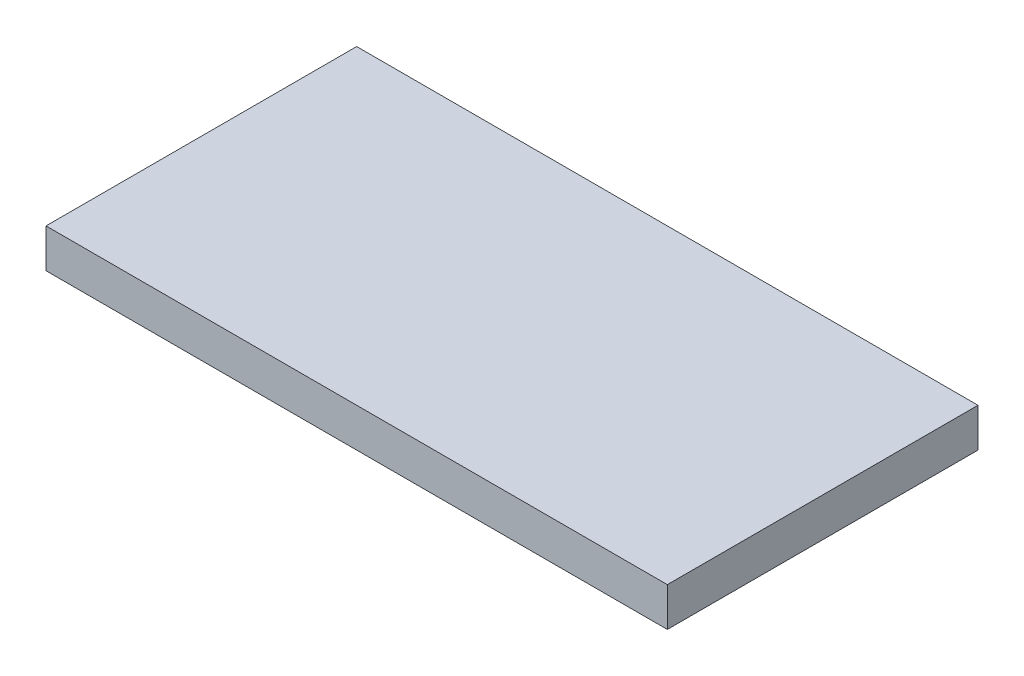
from build123d import *

# Parameters (mm, degrees)
SKETCH1_W           = 203.2
SKETCH1_H           = 101.6
BOSS_EXTRUDE1_DEPTH = 6.35


with BuildPart() as part:
    # Sketch1 → Boss-Extrude1 (new body, symmetric)
    with BuildSketch(Plane(origin=(0, 0, 0), x_dir=(1, 0, 0), z_dir=(0, 1, 0))):
        Rectangle(SKETCH1_W, SKETCH1_H)
    extrude(amount=BOSS_EXTRUDE1_DEPTH, both=True)


solid = part.part
